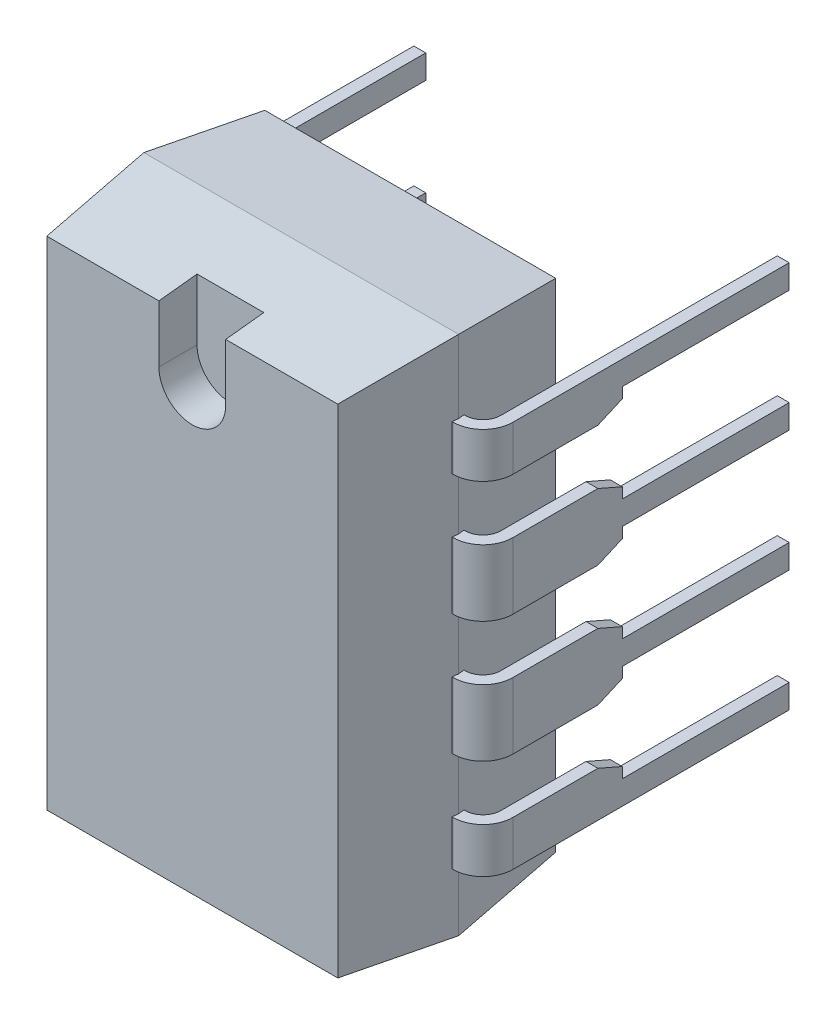
from build123d import *

# Parameters (mm, degrees)
BASIC_SHAPE_DEPTH              = 5.46
SIDE_PROFILE1_DEPTH            = 4.3
SIDE_PROFILE1_DEPTH_BACK       = 4.3
SIDE_PROFILE2_DEPTH            = 4.3
SIDE_PROFILE2_DEPTH_BACK       = 4.3
LOCATION_MARK_DEPTH            = 0.8
SKETCH6_W                      = 0.25
SKETCH6_H                      = 1.39
PIN_RELIEF_DEPTH               = 8.235
REMAINING_PINS_COUNT           = 4
REMAINING_PINS_PITCH           = 2.54
REMAINING_PINS_COPY_1_SKETCH_W = 0.25
REMAINING_PINS_COPY_1_SKETCH_H = 1.39
REMAINING_PINS_COPY_2_SKETCH_W = 0.25
REMAINING_PINS_COPY_2_SKETCH_H = 1.39
REMAINING_PINS_COPY_3_SKETCH_W = 0.25
REMAINING_PINS_COPY_3_SKETCH_H = 1.39
REMAINING_PINS_COPY_4_DEPTH    = 8.235
REMAINING_PINS_COPY_5_DEPTH    = 8.235
REMAINING_PINS_COPY_6_DEPTH    = 8.235
PIN_SHAPE1_DEPTH               = 0.445
PIN_SHAPE2_DEPTH               = 0.445


with BuildPart() as part:
    # Sketch1 → Basic Shape (new body, symmetric)
    with BuildSketch(Plane(origin=(0, 0, 0), x_dir=(1, 0, 0), z_dir=(0, 1, 0))):
        Polygon((-3.05, -0.51), (-3.3, -2.795), (-3.05, -5.08), (3.05, -5.08), (3.3, -2.795), (3.05, -0.51), align=None)
    extrude(amount=BASIC_SHAPE_DEPTH, both=True)

    # Sketch2 → Side Profile1 (cut, two sides)
    with BuildSketch(Plane(origin=(0, 0, 0), x_dir=(0, 0, -1), z_dir=(1, 0, 0))) as side_profile1_sk:
        Polygon((-5.08, 5.46), (-5.08, 5.21), (-2.795, 5.46), align=None)
        Polygon((-5.08, -5.46), (-2.795, -5.46), (-5.08, -5.21), align=None)
    extrude(amount=SIDE_PROFILE1_DEPTH, mode=Mode.SUBTRACT)
    extrude(side_profile1_sk.sketch, amount=-SIDE_PROFILE1_DEPTH_BACK, mode=Mode.SUBTRACT)

    # Sketch3 → Side Profile2 (cut, two sides)
    with BuildSketch(Plane(origin=(0, 0, 0), x_dir=(0, 0, -1), z_dir=(1, 0, 0))) as side_profile2_sk:
        Polygon((-2.795, 5.46), (-0.51, 5.46), (-0.51, 5.21), align=None)
        Polygon((-2.795, -5.46), (-0.51, -5.46), (-0.51, -5.21), align=None)
    extrude(amount=SIDE_PROFILE2_DEPTH, mode=Mode.SUBTRACT)
    extrude(side_profile2_sk.sketch, amount=-SIDE_PROFILE2_DEPTH_BACK, mode=Mode.SUBTRACT)

    # Sketch4 → Location Mark (cut)
    with BuildSketch(Plane(origin=(0, 0, 5.08), x_dir=(-1, 0, 0), z_dir=(0, 0, -1))):
        with BuildLine():
            Line((0.7, 6.21), (-0.7, 6.21))
            Line((-0.7, 6.21), (-0.7, 5.21))
            Line((-0.7, 5.21), (-0.7, 4.01))
            ThreePointArc((-0.7, 4.01), (0, 3.31), (0.7, 4.01))
            Line((0.7, 4.01), (0.7, 5.21))
            Line((0.7, 5.21), (0.7, 6.21))
        make_face()
    extrude(amount=LOCATION_MARK_DEPTH, mode=Mode.SUBTRACT)

    # First Pin: sweep along a path in Sketch5
    with BuildLine(Plane(origin=(0, -3.94, 0), x_dir=(1, 0, 0), z_dir=(0, 1, 0))) as first_pin_path:
        Line((0, -2.795), (3.31, -2.795))
        ThreePointArc((3.31, -2.795), (3.663553391, -2.648553391), (3.81, -2.295))
        Line((3.81, -2.295), (3.81, 3.5))
    # Sketch6 → First Pin (sweep)
    with BuildSketch(Plane(origin=(0, 0, 0), x_dir=(0, 0, -1), z_dir=(1, 0, 0))):
        with Locations((-2.795, -3.94)):
            Rectangle(SKETCH6_W, SKETCH6_H)
    first_pin = sweep(path=first_pin_path.line)

    # Sketch7 → Pin Relief (cut, through all)
    with BuildSketch(Plane(origin=(3.935, 0, 0), x_dir=(0, 0, -1), z_dir=(1, 0, 0))):
        Polygon((0, -4.19), (3.5, -4.19), (3.5, -4.635), (-0.51, -4.635), (0, -4.4125), align=None)
        Polygon((0, -3.69), (3.5, -3.69), (3.5, -3.245), (-0.51, -3.245), (0, -3.4675), align=None)
    pin_relief = extrude(amount=-PIN_RELIEF_DEPTH, mode=Mode.SUBTRACT)

    # Opp Pin: First Pin, Pin Relief across plane
    add(first_pin.mirror(Plane(origin=(0, 0, 0), x_dir=(0, 0, 1), z_dir=(1, 0, 0))))
    add(pin_relief.mirror(Plane(origin=(0, 0, 0), x_dir=(0, 0, 1), z_dir=(1, 0, 0))), mode=Mode.SUBTRACT)

    # Remaining Pins: First Pin, Pin Relief ×4
    with Locations(*[(0, i * REMAINING_PINS_PITCH, 0) for i in range(1, REMAINING_PINS_COUNT)]):
        add(first_pin)
        add(pin_relief, mode=Mode.SUBTRACT)

    # Remaining Pins copy 1: sweep along a path in Remaining Pins copy 1 path
    with BuildLine(Plane(origin=(0, -1.4, 0), x_dir=(-1, 0, 0), z_dir=(0, 1, 0))) as remaining_pins_copy_1_path:
        Line((0, 2.795), (3.31, 2.795))
        ThreePointArc((3.31, 2.795), (3.663553391, 2.648553391), (3.81, 2.295))
        Line((3.81, 2.295), (3.81, -3.5))
    # Remaining Pins copy 1 sketch → Remaining Pins copy 1 (sweep)
    with BuildSketch(Plane(origin=(0, 2.54, 0), x_dir=(0, 0, -1), z_dir=(-1, 0, 0))):
        with Locations((-2.795, 3.94)):
            Rectangle(REMAINING_PINS_COPY_1_SKETCH_W, REMAINING_PINS_COPY_1_SKETCH_H)
    sweep(path=remaining_pins_copy_1_path.line)

    # Remaining Pins copy 2: sweep along a path in Remaining Pins copy 2 path
    with BuildLine(Plane(origin=(0, 1.14, 0), x_dir=(-1, 0, 0), z_dir=(0, 1, 0))) as remaining_pins_copy_2_path:
        Line((0, 2.795), (3.31, 2.795))
        ThreePointArc((3.31, 2.795), (3.663553391, 2.648553391), (3.81, 2.295))
        Line((3.81, 2.295), (3.81, -3.5))
    # Remaining Pins copy 2 sketch → Remaining Pins copy 2 (sweep)
    with BuildSketch(Plane(origin=(0, 5.08, 0), x_dir=(0, 0, -1), z_dir=(-1, 0, 0))):
        with Locations((-2.795, 3.94)):
            Rectangle(REMAINING_PINS_COPY_2_SKETCH_W, REMAINING_PINS_COPY_2_SKETCH_H)
    sweep(path=remaining_pins_copy_2_path.line)

    # Remaining Pins copy 3: sweep along a path in Remaining Pins copy 3 path
    with BuildLine(Plane(origin=(0, 3.68, 0), x_dir=(-1, 0, 0), z_dir=(0, 1, 0))) as remaining_pins_copy_3_path:
        Line((0, 2.795), (3.31, 2.795))
        ThreePointArc((3.31, 2.795), (3.663553391, 2.648553391), (3.81, 2.295))
        Line((3.81, 2.295), (3.81, -3.5))
    # Remaining Pins copy 3 sketch → Remaining Pins copy 3 (sweep)
    with BuildSketch(Plane(origin=(0, 7.62, 0), x_dir=(0, 0, -1), z_dir=(-1, 0, 0))):
        with Locations((-2.795, 3.94)):
            Rectangle(REMAINING_PINS_COPY_3_SKETCH_W, REMAINING_PINS_COPY_3_SKETCH_H)
    sweep(path=remaining_pins_copy_3_path.line)

    # Remaining Pins copy 4 sketch → Remaining Pins copy 4 (cut, through all)
    with BuildSketch(Plane(origin=(-3.935, 2.54, 0), x_dir=(0, 0, -1), z_dir=(-1, 0, 0))):
        Polygon((0, 4.19), (3.5, 4.19), (3.5, 4.635), (-0.51, 4.635), (0, 4.4125), align=None)
        Polygon((0, 3.69), (3.5, 3.69), (3.5, 3.245), (-0.51, 3.245), (0, 3.4675), align=None)
    extrude(amount=-REMAINING_PINS_COPY_4_DEPTH, mode=Mode.SUBTRACT)

    # Remaining Pins copy 5 sketch → Remaining Pins copy 5 (cut, through all)
    with BuildSketch(Plane(origin=(-3.935, 5.08, 0), x_dir=(0, 0, -1), z_dir=(-1, 0, 0))):
        Polygon((0, 4.19), (3.5, 4.19), (3.5, 4.635), (-0.51, 4.635), (0, 4.4125), align=None)
        Polygon((0, 3.69), (3.5, 3.69), (3.5, 3.245), (-0.51, 3.245), (0, 3.4675), align=None)
    extrude(amount=-REMAINING_PINS_COPY_5_DEPTH, mode=Mode.SUBTRACT)

    # Remaining Pins copy 6 sketch → Remaining Pins copy 6 (cut, through all)
    with BuildSketch(Plane(origin=(-3.935, 7.62, 0), x_dir=(0, 0, -1), z_dir=(-1, 0, 0))):
        Polygon((0, 4.19), (3.5, 4.19), (3.5, 4.635), (-0.51, 4.635), (0, 4.4125), align=None)
        Polygon((0, 3.69), (3.5, 3.69), (3.5, 3.245), (-0.51, 3.245), (0, 3.4675), align=None)
    extrude(amount=-REMAINING_PINS_COPY_6_DEPTH, mode=Mode.SUBTRACT)

    # Sketch9 → Pin Shape1 (cut)
    with BuildSketch(Plane.XZ.offset(4.635)):
        with BuildLine():
            Line((3.935, 0), (3.685, 0))
            Line((3.685, 0), (3.685, 2.295))
            ThreePointArc((3.685, 2.295), (3.575165043, 2.560165043), (3.31, 2.67))
            Line((3.31, 2.67), (3.286323851, 2.67))
            Line((3.286323851, 2.67), (3.3, 2.795))
            Line((3.3, 2.795), (3.286323851, 2.92))
            Line((3.286323851, 2.92), (3.31, 2.92))
            ThreePointArc((3.31, 2.92), (3.751941738, 2.736941738), (3.935, 2.295))
            Line((3.935, 2.295), (3.935, 0))
        make_face()
        with BuildLine():
            Line((-3.685, 0), (-3.935, 0))
            Line((-3.935, 0), (-3.935, 2.295))
            ThreePointArc((-3.935, 2.295), (-3.751941738, 2.736941738), (-3.31, 2.92))
            Line((-3.31, 2.92), (-3.286323851, 2.92))
            Line((-3.286323851, 2.92), (-3.3, 2.795))
            Line((-3.3, 2.795), (-3.286323851, 2.67))
            Line((-3.286323851, 2.67), (-3.31, 2.67))
            ThreePointArc((-3.31, 2.67), (-3.575165043, 2.560165043), (-3.685, 2.295))
            Line((-3.685, 2.295), (-3.685, 0))
        make_face()
    extrude(amount=-PIN_SHAPE1_DEPTH, mode=Mode.SUBTRACT)

    # Sketch10 → Pin Shape2 (cut)
    with BuildSketch(Plane(origin=(0, 4.375, 0), x_dir=(-1, 0, 0), z_dir=(0, 1, 0))):
        with BuildLine():
            Line((3.685, 0), (3.935, 0))
            Line((3.935, 0), (3.935, 2.295))
            ThreePointArc((3.935, 2.295), (3.751941738, 2.736941738), (3.31, 2.92))
            Line((3.31, 2.92), (3.286323851, 2.92))
            Line((3.286323851, 2.92), (3.3, 2.795))
            Line((3.3, 2.795), (3.286323851, 2.67))
            Line((3.286323851, 2.67), (3.31, 2.67))
            ThreePointArc((3.31, 2.67), (3.575165043, 2.560165043), (3.685, 2.295))
            Line((3.685, 2.295), (3.685, 0))
        make_face()
        with BuildLine():
            Line((-3.685, 0), (-3.935, 0))
            Line((-3.935, 0), (-3.935, 2.295))
            ThreePointArc((-3.935, 2.295), (-3.751941738, 2.736941738), (-3.31, 2.92))
            Line((-3.31, 2.92), (-3.286323851, 2.92))
            Line((-3.286323851, 2.92), (-3.3, 2.795))
            Line((-3.3, 2.795), (-3.286323851, 2.67))
            Line((-3.286323851, 2.67), (-3.31, 2.67))
            ThreePointArc((-3.31, 2.67), (-3.575165043, 2.560165043), (-3.685, 2.295))
            Line((-3.685, 2.295), (-3.685, 0))
        make_face()
    extrude(amount=-PIN_SHAPE2_DEPTH, mode=Mode.SUBTRACT)


solid = part.part
